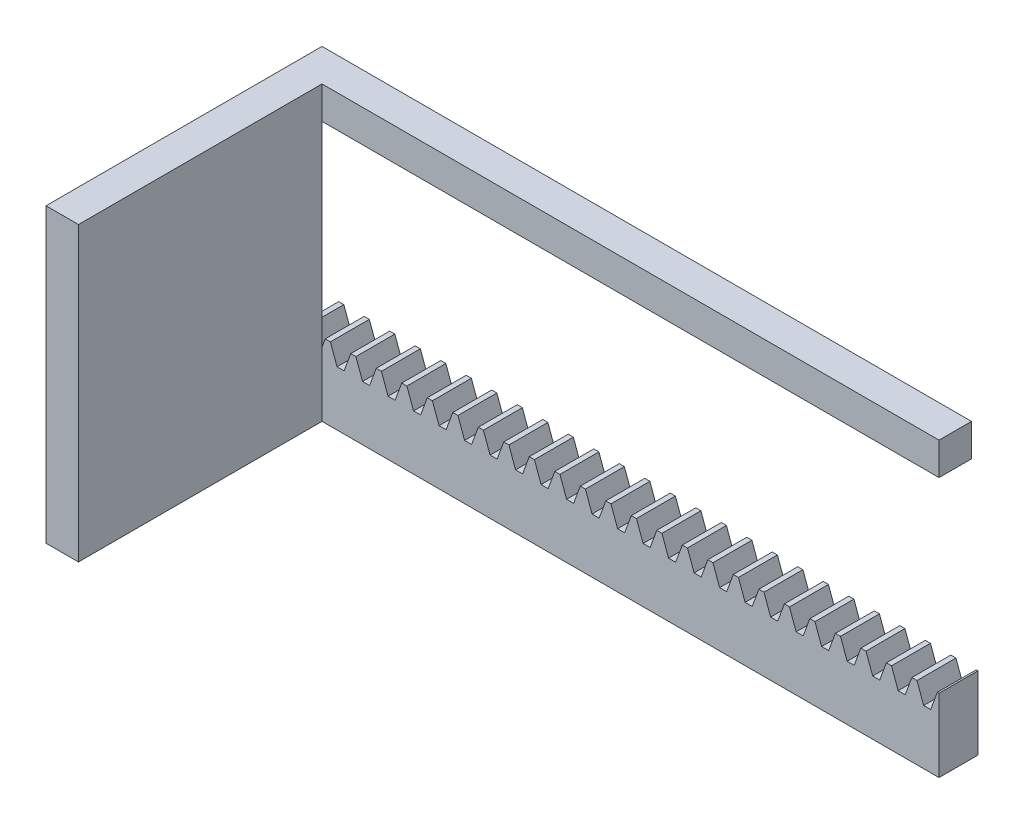
from build123d import *

# Parameters (mm, degrees)
BLANKSKE_W          = 200
BLANKSKE_H          = 22.5
BLANK_DEPTH         = 12
TOOTHCUTSIM_DEPTH   = 202.619071519
TEETHCUTS_COUNT     = 26
TEETHCUTS_PITCH     = 7.853981625
SKETCH2_W           = 10
SKETCH2_H           = 90
BOSS_EXTRUDE1_DEPTH = 75
SKETCH3_W           = 200
SKETCH3_H           = 10
BOSS_EXTRUDE2_DEPTH = 10


with BuildPart() as part:
    # BlankSke → Blank (new body)
    with BuildSketch(Plane.XY):
        with Locations((100, 11.25)):
            Rectangle(BLANKSKE_W, BLANKSKE_H)
    extrude(amount=-BLANK_DEPTH)

    # TooCutSkeSim → ToothCutSim (cut, through all)
    with BuildSketch(Plane.XY):
        Polygon((1.087088424, 16.875), (-1.087088424, 16.875), (-3.143665836, 22.5254), (3.143665836, 22.5254), align=None)
    toothcutsim = extrude(amount=-TOOTHCUTSIM_DEPTH, mode=Mode.SUBTRACT)

    # TeethCuts: ToothCutSim ×26
    with Locations(*[(i * TEETHCUTS_PITCH, 0, 0) for i in range(1, TEETHCUTS_COUNT)]):
        add(toothcutsim, mode=Mode.SUBTRACT)

    # Sketch2 → Boss-Extrude1 (add)
    with BuildSketch(Plane.XY):
        with Locations((5, 45)):
            Rectangle(SKETCH2_W, SKETCH2_H)
    extrude(amount=BOSS_EXTRUDE1_DEPTH)

    # Sketch3 → Boss-Extrude2 (add)
    with BuildSketch(Plane(origin=(0, 0, 0), x_dir=(-1, 0, 0), z_dir=(0, 0, -1))):
        with Locations((-100, 85)):
            Rectangle(SKETCH3_W, SKETCH3_H)
    extrude(amount=BOSS_EXTRUDE2_DEPTH)


solid = part.part
